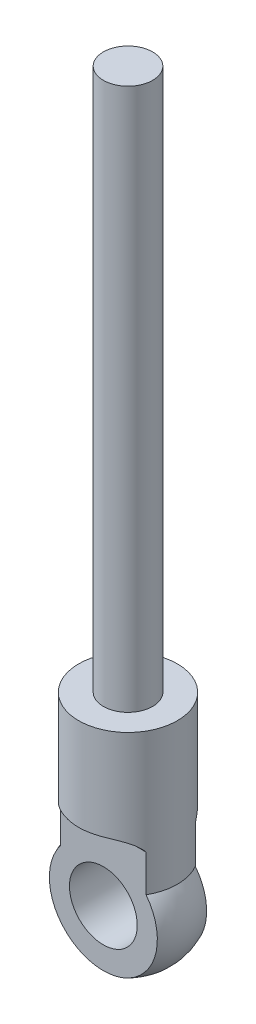
from build123d import *

# Parameters (mm, degrees)
CUT_EXTRUDE1_DEPTH      = 5.816666667
CUT_EXTRUDE1_DEPTH_BACK = 10
SKETCH3_R               = 2.75
CUT_EXTRUDE2_DEPTH      = 3.0000001
CUT_EXTRUDE2_DEPTH_BACK = 7.0000001


with BuildPart() as part:
    # Sketch1 → Revolve1 (revolve)
    with BuildSketch(Plane.XY):
        with BuildLine():
            Line((0, 0), (0, 44))
            Line((0, 44), (-2, 44))
            Line((-2, 44), (-2, 0))
            Line((-2, 0), (-4, 0))
            Line((-4, 0), (-4, -11.5))
            ThreePointArc((-4, -11.5), (-4.25, -16.45), (0, -19))
            Line((0, -19), (0, 0))
        make_face()
    revolve(axis=Axis((0, 0, 0), (0, 1, 0)))

    # Sketch2 → Cut-Extrude1 (cut, two sides)
    with BuildSketch(Plane(origin=(0, 0, 0), x_dir=(0, 0, -1), z_dir=(1, 0, 0))) as cut_extrude1_sk:
        with BuildLine():
            ThreePointArc((-2, -8.5), (-2.881966011, -7.763932023), (-4, -7.5))
            Line((-4, -7.5), (-4, -8.077978136))
            ThreePointArc((-4, -8.077978136), (-6.041123222, -13.901532194), (-2, -18.56514549))
            Line((-2, -18.56514549), (-2, -11.5))
            Line((-2, -11.5), (-2, -8.5))
        make_face()
        with BuildLine():
            Line((4, -8.077978136), (4, -7.5))
            ThreePointArc((4, -7.5), (2.881966011, -7.763932023), (2, -8.5))
            Line((2, -8.5), (2, -11.5))
            Line((2, -11.5), (2, -18.56514549))
            ThreePointArc((2, -18.56514549), (6.041123222, -13.901532194), (4, -8.077978136))
        make_face()
    extrude(amount=CUT_EXTRUDE1_DEPTH, mode=Mode.SUBTRACT)
    extrude(cut_extrude1_sk.sketch, amount=-CUT_EXTRUDE1_DEPTH_BACK, mode=Mode.SUBTRACT)

    # Sketch3 → Cut-Extrude2 (cut, two sides)
    with BuildSketch(Plane.XY.offset(2)) as cut_extrude2_sk:
        with Locations((0, -14)):
            Circle(SKETCH3_R)
    extrude(amount=CUT_EXTRUDE2_DEPTH, mode=Mode.SUBTRACT)
    extrude(cut_extrude2_sk.sketch, amount=-CUT_EXTRUDE2_DEPTH_BACK, mode=Mode.SUBTRACT)


solid = part.part
